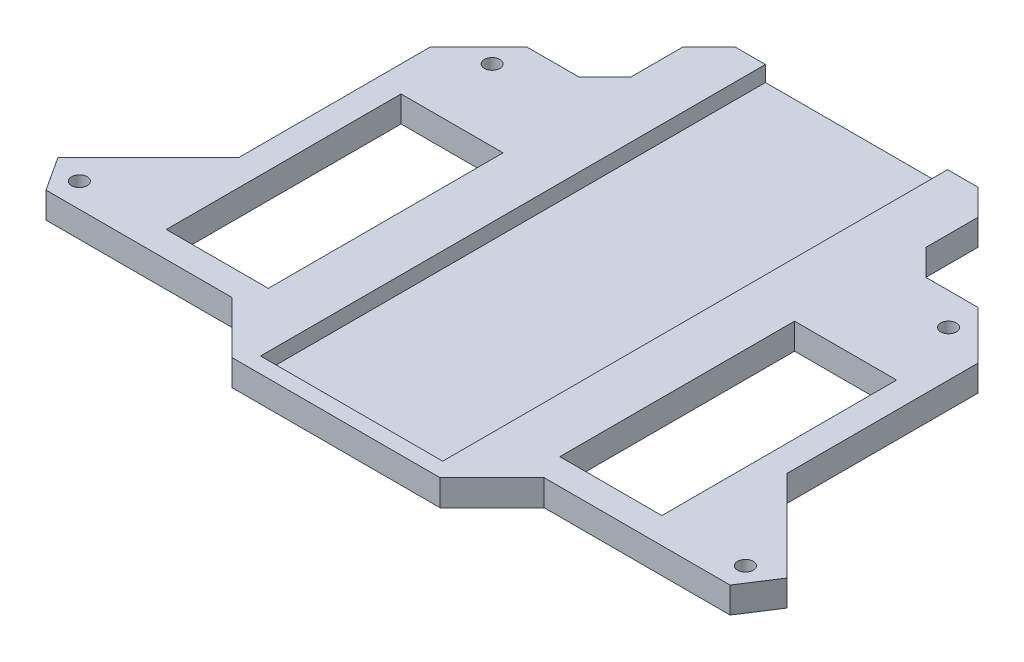
from build123d import *

# Parameters (mm, degrees)
SKETCH1_R           = 1.5
SKETCH1_W           = 19.6
SKETCH1_H           = 45.1
BOSS_EXTRUDE1_DEPTH = 5
CUT_EXTRUDE2_DEPTH  = 5
SKETCH2_W           = 35
SKETCH2_H           = 97
CUT_EXTRUDE1_DEPTH  = 3


with BuildPart() as part:
    # Sketch1 → Boss-Extrude1 (new body)
    with BuildSketch(Plane(origin=(0, 0, 0), x_dir=(1, 0, 0), z_dir=(0, 1, 0))):
        Polygon((-59.213749531, -30), (-70, -13.390630812), (-70, 23.338095117), (-23.338095117, 70), (0, 70), (0, -30), align=None)
        with Locations((-43.840620434, 43.840620434)):
            Circle(SKETCH1_R, mode=Mode.SUBTRACT)
        with Locations((-63.979633983, -15.316867676)):
            Circle(SKETCH1_R, mode=Mode.SUBTRACT)
        with Locations((-37.8, 7.55)):
            Rectangle(SKETCH1_W, SKETCH1_H, mode=Mode.SUBTRACT)
    boss_extrude1 = extrude(amount=BOSS_EXTRUDE1_DEPTH)

    # Sketch3 → Cut-Extrude2 (cut)
    with BuildSketch(Plane(origin=(0, 5, 0), x_dir=(1, 0, 0), z_dir=(0, 1, 0))):
        Polygon((-20, -30), (-30, -20), (-65.707825463, -20), (-70, -13.390630812), (-52.6, 4.009369188), (-52.6, 40.738095117), (-43.338095117, 50), (-33.338095117, 50), (-28.338095117, 55), (-28.338095117, 65), (-75, 65), (-75, -30), align=None)
    cut_extrude2 = extrude(amount=-CUT_EXTRUDE2_DEPTH, mode=Mode.SUBTRACT)

    # Mirror1: Boss-Extrude1, Cut-Extrude2 across plane
    add(boss_extrude1.mirror(Plane(origin=(0, 5, 30), x_dir=(0, 0, 1), z_dir=(-1, 0, 0))))
    add(cut_extrude2.mirror(Plane(origin=(0, 5, 30), x_dir=(0, 0, 1), z_dir=(-1, 0, 0))), mode=Mode.SUBTRACT)

    # Sketch2 → Cut-Extrude1 (cut)
    with BuildSketch(Plane(origin=(0, 5, 0), x_dir=(1, 0, 0), z_dir=(0, 1, 0))):
        with Locations((0, 21.5)):
            Rectangle(SKETCH2_W, SKETCH2_H)
    extrude(amount=-CUT_EXTRUDE1_DEPTH, mode=Mode.SUBTRACT)


solid = part.part
